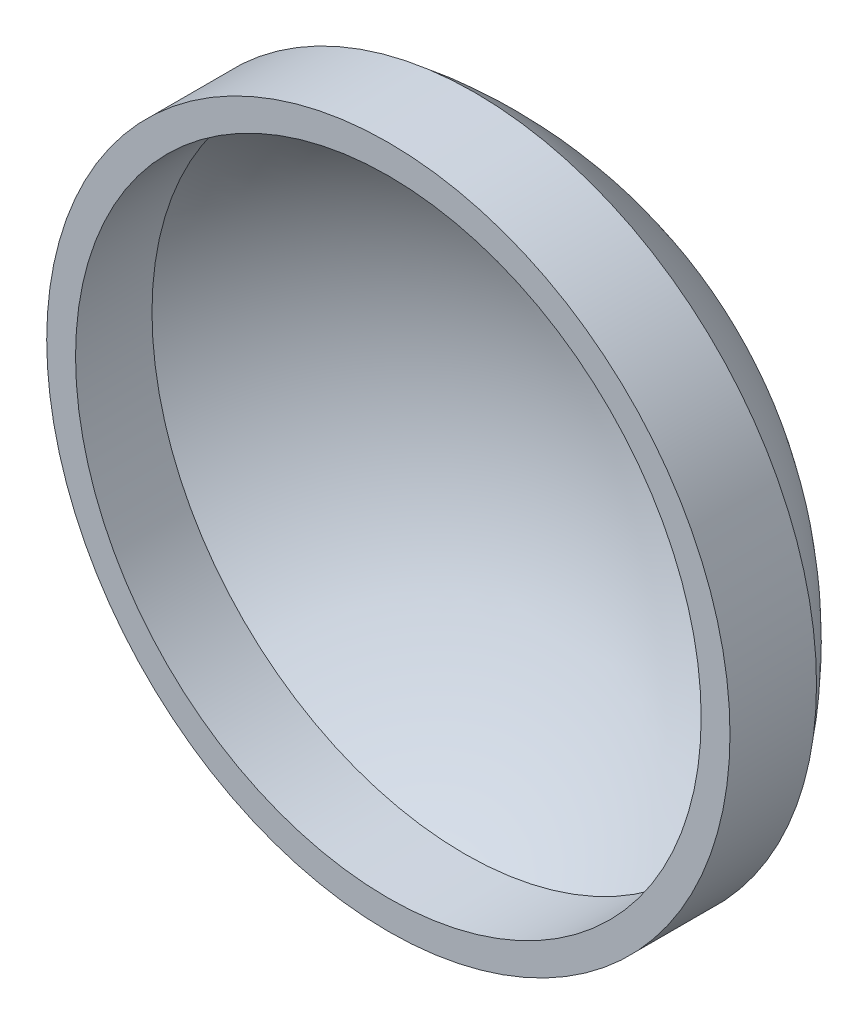
from build123d import *

# Parameters (mm, degrees)
SHELL4_T = -2.54


with BuildPart() as part:
    # Sketch4 → Revolve1 (revolve)
    with BuildSketch(Plane(origin=(0, 0, 0), x_dir=(1, 0, 0), z_dir=(0, 1, 0))):
        with BuildLine():
            Line((0, 38.1), (0, 15.748))
            Line((0, 15.748), (30.092300942, 15.748))
            Line((30.092300942, 15.748), (30.092300942, 23.368))
            ThreePointArc((30.092300942, 23.368), (16.752450567, 34.219371707), (0, 38.1))
        make_face()
    revolve(axis=Axis((0, 0, 0), (0, 0, -1)))

    # Shell4
    shell4_openings = [part.faces().sort_by_distance(p)[0] for p in [
        (30.092300942, 0, -15.748),
    ]]
    offset(amount=SHELL4_T, openings=shell4_openings, kind=Kind.INTERSECTION)


solid = part.part
